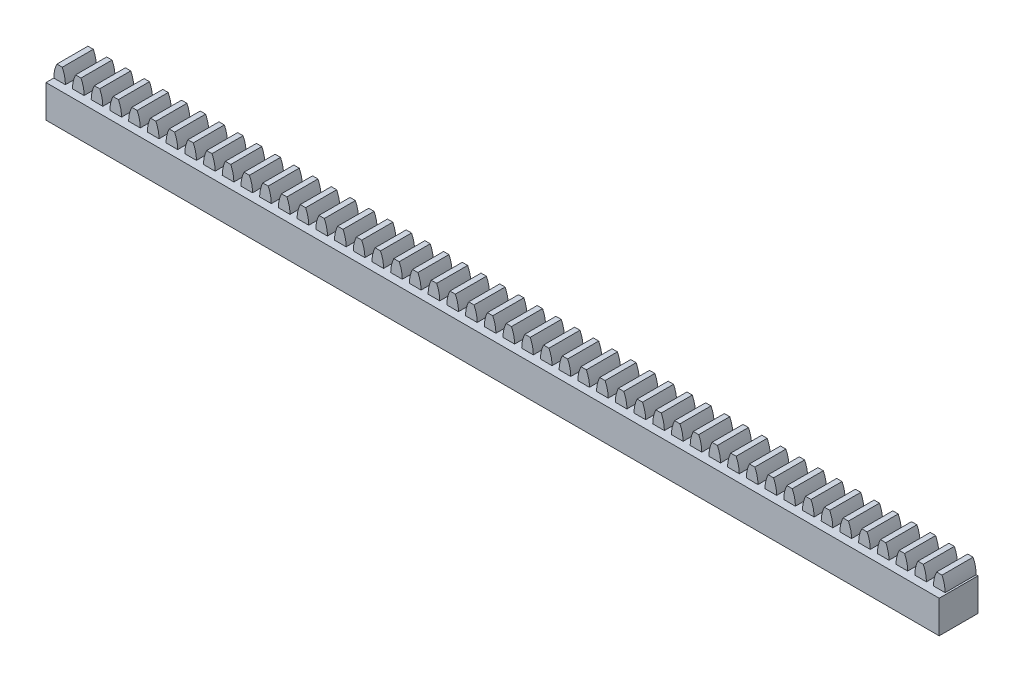
from build123d import *

# Parameters (mm, degrees)
RESSALTO_EXTRUS_O1_DEPTH      = 2
RESSALTO_EXTRUS_O1_2_DEPTH    = 2
RESSALTO_EXTRUS_O1_3_DEPTH    = 2
RESSALTO_EXTRUS_O1_4_DEPTH    = 2
RESSALTO_EXTRUS_O1_5_DEPTH    = 2
RESSALTO_EXTRUS_O1_6_DEPTH    = 2
RESSALTO_EXTRUS_O1_7_DEPTH    = 2
RESSALTO_EXTRUS_O1_8_DEPTH    = 2
RESSALTO_EXTRUS_O1_9_DEPTH    = 2
RESSALTO_EXTRUS_O1_10_DEPTH   = 2
RESSALTO_EXTRUS_O1_11_DEPTH   = 2
RESSALTO_EXTRUS_O1_12_DEPTH   = 2
RESSALTO_EXTRUS_O1_13_DEPTH   = 2
RESSALTO_EXTRUS_O1_14_DEPTH   = 2
RESSALTO_EXTRUS_O1_15_DEPTH   = 2
RESSALTO_EXTRUS_O1_16_DEPTH   = 2
RESSALTO_EXTRUS_O1_17_DEPTH   = 2
RESSALTO_EXTRUS_O1_18_DEPTH   = 2
RESSALTO_EXTRUS_O1_19_DEPTH   = 2
RESSALTO_EXTRUS_O1_20_DEPTH   = 2
RESSALTO_EXTRUS_O1_21_DEPTH   = 2
RESSALTO_EXTRUS_O1_22_DEPTH   = 2
RESSALTO_EXTRUS_O1_23_DEPTH   = 2
RESSALTO_EXTRUS_O1_24_DEPTH   = 2
RESSALTO_EXTRUS_O1_25_DEPTH   = 2
RESSALTO_EXTRUS_O1_26_DEPTH   = 2
RESSALTO_EXTRUS_O1_27_DEPTH   = 2
RESSALTO_EXTRUS_O1_28_DEPTH   = 2
RESSALTO_EXTRUS_O1_29_DEPTH   = 2
RESSALTO_EXTRUS_O1_30_DEPTH   = 2
RESSALTO_EXTRUS_O1_31_DEPTH   = 2
RESSALTO_EXTRUS_O1_32_DEPTH   = 2
RESSALTO_EXTRUS_O1_33_DEPTH   = 2
RESSALTO_EXTRUS_O1_34_DEPTH   = 2
RESSALTO_EXTRUS_O1_35_DEPTH   = 2
RESSALTO_EXTRUS_O1_36_DEPTH   = 2
RESSALTO_EXTRUS_O1_37_DEPTH   = 2
RESSALTO_EXTRUS_O1_38_DEPTH   = 2
RESSALTO_EXTRUS_O1_39_DEPTH   = 2
RESSALTO_EXTRUS_O1_40_DEPTH   = 2
RESSALTO_EXTRUS_O1_41_DEPTH   = 2
RESSALTO_EXTRUS_O1_42_DEPTH   = 2
RESSALTO_EXTRUS_O1_43_DEPTH   = 2
RESSALTO_EXTRUS_O1_44_DEPTH   = 2
RESSALTO_EXTRUS_O1_45_DEPTH   = 2
RESSALTO_EXTRUS_O1_46_DEPTH   = 2
RESSALTO_EXTRUS_O1_47_DEPTH   = 2
RESSALTO_EXTRUS_O1_48_DEPTH   = 2
RESSALTO_EXTRUS_O2_DEPTH      = 3
RESSALTO_EXTRUS_O2_DEPTH_BACK = 2
ESBO_O1_7_W                   = 115
ESBO_O1_7_H                   = 4.2


with BuildPart() as part:
    # Esboço1 → Ressalto-extrusão1 (new, symmetric)
    with BuildSketch(Plane.XY):
        with BuildLine():
            Line((-1.017526261, 4.529689969), (-1.711247382, 4.529689969))
            ThreePointArc((-1.711247382, 4.529689969), (-2.010696446, 3.673045524), (-2.112202188, 2.771266155))
            Line((-2.112202188, 2.771266155), (-0.616571456, 2.771266155))
            ThreePointArc((-0.616571456, 2.771266155), (-0.718077198, 3.673045524), (-1.017526261, 4.529689969))
        make_face()
    extrude(amount=RESSALTO_EXTRUS_O1_DEPTH, both=True)



with BuildPart() as body_2:
    # Esboço1 → Ressalto-extrus_o1 2 (new, symmetric)
    with BuildSketch(Plane.XY):
        with BuildLine():
            ThreePointArc((0.698752618, 4.529689969), (0.399303554, 3.673045524), (0.297797812, 2.771266155))
            Line((0.297797812, 2.771266155), (1.793428544, 2.771266155))
            ThreePointArc((1.793428544, 2.771266155), (1.691922802, 3.673045524), (1.392473739, 4.529689969))
            Line((1.392473739, 4.529689969), (0.698752618, 4.529689969))
        make_face()
    extrude(amount=RESSALTO_EXTRUS_O1_2_DEPTH, both=True)


with BuildPart() as body_3:
    # Esboço1 → Ressalto-extrus_o1 3 (new, symmetric)
    with BuildSketch(Plane.XY):
        with BuildLine():
            ThreePointArc((3.108752618, 4.529689969), (2.809303554, 3.673045524), (2.707797812, 2.771266155))
            Line((2.707797812, 2.771266155), (4.203428544, 2.771266155))
            ThreePointArc((4.203428544, 2.771266155), (4.101922802, 3.673045524), (3.802473739, 4.529689969))
            Line((3.802473739, 4.529689969), (3.108752618, 4.529689969))
        make_face()
    extrude(amount=RESSALTO_EXTRUS_O1_3_DEPTH, both=True)


with BuildPart() as body_4:
    # Esboço1 → Ressalto-extrus_o1 4 (new, symmetric)
    with BuildSketch(Plane.XY):
        with BuildLine():
            ThreePointArc((77.818752618, 4.529689969), (77.519303554, 3.673045524), (77.417797812, 2.771266155))
            Line((77.417797812, 2.771266155), (78.913428544, 2.771266155))
            ThreePointArc((78.913428544, 2.771266155), (78.811922802, 3.673045524), (78.512473739, 4.529689969))
            Line((78.512473739, 4.529689969), (77.818752618, 4.529689969))
        make_face()
    extrude(amount=RESSALTO_EXTRUS_O1_4_DEPTH, both=True)


with BuildPart() as body_5:
    # Esboço1 → Ressalto-extrus_o1 5 (new, symmetric)
    with BuildSketch(Plane.XY):
        with BuildLine():
            Line((75.007797812, 2.771266155), (76.503428544, 2.771266155))
            ThreePointArc((76.503428544, 2.771266155), (76.401922802, 3.673045524), (76.102473739, 4.529689969))
            Line((76.102473739, 4.529689969), (75.408752618, 4.529689969))
            ThreePointArc((75.408752618, 4.529689969), (75.109303554, 3.673045524), (75.007797812, 2.771266155))
        make_face()
    extrude(amount=RESSALTO_EXTRUS_O1_5_DEPTH, both=True)


with BuildPart() as body_6:
    # Esboço1 → Ressalto-extrus_o1 6 (new, symmetric)
    with BuildSketch(Plane.XY):
        with BuildLine():
            ThreePointArc((5.518752618, 4.529689969), (5.219303554, 3.673045524), (5.117797812, 2.771266155))
            Line((5.117797812, 2.771266155), (6.613428544, 2.771266155))
            ThreePointArc((6.613428544, 2.771266155), (6.511922802, 3.673045524), (6.212473739, 4.529689969))
            Line((6.212473739, 4.529689969), (5.518752618, 4.529689969))
        make_face()
    extrude(amount=RESSALTO_EXTRUS_O1_6_DEPTH, both=True)


with BuildPart() as body_7:
    # Esboço1 → Ressalto-extrus_o1 7 (new, symmetric)
    with BuildSketch(Plane.XY):
        with BuildLine():
            ThreePointArc((80.228752618, 4.529689969), (79.929303554, 3.673045524), (79.827797812, 2.771266155))
            Line((79.827797812, 2.771266155), (81.323428544, 2.771266155))
            ThreePointArc((81.323428544, 2.771266155), (81.221922802, 3.673045524), (80.922473739, 4.529689969))
            Line((80.922473739, 4.529689969), (80.228752618, 4.529689969))
        make_face()
    extrude(amount=RESSALTO_EXTRUS_O1_7_DEPTH, both=True)


with BuildPart() as body_8:
    # Esboço1 → Ressalto-extrus_o1 8 (new, symmetric)
    with BuildSketch(Plane.XY):
        with BuildLine():
            Line((111.157797812, 2.771266155), (112.653428544, 2.771266155))
            ThreePointArc((112.653428544, 2.771266155), (112.551922802, 3.673045524), (112.252473739, 4.529689969))
            Line((112.252473739, 4.529689969), (111.558752618, 4.529689969))
            ThreePointArc((111.558752618, 4.529689969), (111.259303554, 3.673045524), (111.157797812, 2.771266155))
        make_face()
    extrude(amount=RESSALTO_EXTRUS_O1_8_DEPTH, both=True)


with BuildPart() as body_9:
    # Esboço1 → Ressalto-extrus_o1 9 (new, symmetric)
    with BuildSketch(Plane.XY):
        with BuildLine():
            Line((72.597797812, 2.771266155), (74.093428544, 2.771266155))
            ThreePointArc((74.093428544, 2.771266155), (73.991922802, 3.673045524), (73.692473739, 4.529689969))
            Line((73.692473739, 4.529689969), (72.998752618, 4.529689969))
            ThreePointArc((72.998752618, 4.529689969), (72.699303554, 3.673045524), (72.597797812, 2.771266155))
        make_face()
    extrude(amount=RESSALTO_EXTRUS_O1_9_DEPTH, both=True)


with BuildPart() as body_10:
    # Esboço1 → Ressalto-extrus_o1 10 (new, symmetric)
    with BuildSketch(Plane.XY):
        with BuildLine():
            ThreePointArc((7.928752618, 4.529689969), (7.629303554, 3.673045524), (7.527797812, 2.771266155))
            Line((7.527797812, 2.771266155), (9.023428544, 2.771266155))
            ThreePointArc((9.023428544, 2.771266155), (8.921922802, 3.673045524), (8.622473739, 4.529689969))
            Line((8.622473739, 4.529689969), (7.928752618, 4.529689969))
        make_face()
    extrude(amount=RESSALTO_EXTRUS_O1_10_DEPTH, both=True)


with BuildPart() as body_11:
    # Esboço1 → Ressalto-extrus_o1 11 (new, symmetric)
    with BuildSketch(Plane.XY):
        with BuildLine():
            ThreePointArc((82.638752618, 4.529689969), (82.339303554, 3.673045524), (82.237797812, 2.771266155))
            Line((82.237797812, 2.771266155), (83.733428544, 2.771266155))
            ThreePointArc((83.733428544, 2.771266155), (83.631922802, 3.673045524), (83.332473739, 4.529689969))
            Line((83.332473739, 4.529689969), (82.638752618, 4.529689969))
        make_face()
    extrude(amount=RESSALTO_EXTRUS_O1_11_DEPTH, both=True)


with BuildPart() as body_12:
    # Esboço1 → Ressalto-extrus_o1 12 (new, symmetric)
    with BuildSketch(Plane.XY):
        with BuildLine():
            Line((108.747797812, 2.771266155), (110.243428544, 2.771266155))
            ThreePointArc((110.243428544, 2.771266155), (110.141922802, 3.673045524), (109.842473739, 4.529689969))
            Line((109.842473739, 4.529689969), (109.148752618, 4.529689969))
            ThreePointArc((109.148752618, 4.529689969), (108.849303554, 3.673045524), (108.747797812, 2.771266155))
        make_face()
    extrude(amount=RESSALTO_EXTRUS_O1_12_DEPTH, both=True)


with BuildPart() as body_13:
    # Esboço1 → Ressalto-extrus_o1 13 (new, symmetric)
    with BuildSketch(Plane.XY):
        with BuildLine():
            Line((70.187797812, 2.771266155), (71.683428544, 2.771266155))
            ThreePointArc((71.683428544, 2.771266155), (71.581922802, 3.673045524), (71.282473739, 4.529689969))
            Line((71.282473739, 4.529689969), (70.588752618, 4.529689969))
            ThreePointArc((70.588752618, 4.529689969), (70.289303554, 3.673045524), (70.187797812, 2.771266155))
        make_face()
    extrude(amount=RESSALTO_EXTRUS_O1_13_DEPTH, both=True)


with BuildPart() as body_14:
    # Esboço1 → Ressalto-extrus_o1 14 (new, symmetric)
    with BuildSketch(Plane.XY):
        with BuildLine():
            ThreePointArc((10.338752618, 4.529689969), (10.039303554, 3.673045524), (9.937797812, 2.771266155))
            Line((9.937797812, 2.771266155), (11.433428544, 2.771266155))
            ThreePointArc((11.433428544, 2.771266155), (11.331922802, 3.673045524), (11.032473739, 4.529689969))
            Line((11.032473739, 4.529689969), (10.338752618, 4.529689969))
        make_face()
    extrude(amount=RESSALTO_EXTRUS_O1_14_DEPTH, both=True)


with BuildPart() as body_15:
    # Esboço1 → Ressalto-extrus_o1 15 (new, symmetric)
    with BuildSketch(Plane.XY):
        with BuildLine():
            ThreePointArc((85.048752618, 4.529689969), (84.749303554, 3.673045524), (84.647797812, 2.771266155))
            Line((84.647797812, 2.771266155), (86.143428544, 2.771266155))
            ThreePointArc((86.143428544, 2.771266155), (86.041922802, 3.673045524), (85.742473739, 4.529689969))
            Line((85.742473739, 4.529689969), (85.048752618, 4.529689969))
        make_face()
    extrude(amount=RESSALTO_EXTRUS_O1_15_DEPTH, both=True)


with BuildPart() as body_16:
    # Esboço1 → Ressalto-extrus_o1 16 (new, symmetric)
    with BuildSketch(Plane.XY):
        with BuildLine():
            Line((106.337797812, 2.771266155), (107.833428544, 2.771266155))
            ThreePointArc((107.833428544, 2.771266155), (107.731922802, 3.673045524), (107.432473739, 4.529689969))
            Line((107.432473739, 4.529689969), (106.738752618, 4.529689969))
            ThreePointArc((106.738752618, 4.529689969), (106.439303554, 3.673045524), (106.337797812, 2.771266155))
        make_face()
    extrude(amount=RESSALTO_EXTRUS_O1_16_DEPTH, both=True)


with BuildPart() as body_17:
    # Esboço1 → Ressalto-extrus_o1 17 (new, symmetric)
    with BuildSketch(Plane.XY):
        with BuildLine():
            Line((67.777797812, 2.771266155), (69.273428544, 2.771266155))
            ThreePointArc((69.273428544, 2.771266155), (69.171922802, 3.673045524), (68.872473739, 4.529689969))
            Line((68.872473739, 4.529689969), (68.178752618, 4.529689969))
            ThreePointArc((68.178752618, 4.529689969), (67.879303554, 3.673045524), (67.777797812, 2.771266155))
        make_face()
    extrude(amount=RESSALTO_EXTRUS_O1_17_DEPTH, both=True)


with BuildPart() as body_18:
    # Esboço1 → Ressalto-extrus_o1 18 (new, symmetric)
    with BuildSketch(Plane.XY):
        with BuildLine():
            ThreePointArc((12.748752618, 4.529689969), (12.449303554, 3.673045524), (12.347797812, 2.771266155))
            Line((12.347797812, 2.771266155), (13.843428544, 2.771266155))
            ThreePointArc((13.843428544, 2.771266155), (13.741922802, 3.673045524), (13.442473739, 4.529689969))
            Line((13.442473739, 4.529689969), (12.748752618, 4.529689969))
        make_face()
    extrude(amount=RESSALTO_EXTRUS_O1_18_DEPTH, both=True)


with BuildPart() as body_19:
    # Esboço1 → Ressalto-extrus_o1 19 (new, symmetric)
    with BuildSketch(Plane.XY):
        with BuildLine():
            ThreePointArc((87.458752618, 4.529689969), (87.159303554, 3.673045524), (87.057797812, 2.771266155))
            Line((87.057797812, 2.771266155), (88.553428544, 2.771266155))
            ThreePointArc((88.553428544, 2.771266155), (88.451922802, 3.673045524), (88.152473739, 4.529689969))
            Line((88.152473739, 4.529689969), (87.458752618, 4.529689969))
        make_face()
    extrude(amount=RESSALTO_EXTRUS_O1_19_DEPTH, both=True)


with BuildPart() as body_20:
    # Esboço1 → Ressalto-extrus_o1 20 (new, symmetric)
    with BuildSketch(Plane.XY):
        with BuildLine():
            Line((103.927797812, 2.771266155), (105.423428544, 2.771266155))
            ThreePointArc((105.423428544, 2.771266155), (105.321922802, 3.673045524), (105.022473739, 4.529689969))
            Line((105.022473739, 4.529689969), (104.328752618, 4.529689969))
            ThreePointArc((104.328752618, 4.529689969), (104.029303554, 3.673045524), (103.927797812, 2.771266155))
        make_face()
    extrude(amount=RESSALTO_EXTRUS_O1_20_DEPTH, both=True)


with BuildPart() as body_21:
    # Esboço1 → Ressalto-extrus_o1 21 (new, symmetric)
    with BuildSketch(Plane.XY):
        with BuildLine():
            Line((65.367797812, 2.771266155), (66.863428544, 2.771266155))
            ThreePointArc((66.863428544, 2.771266155), (66.761922802, 3.673045524), (66.462473739, 4.529689969))
            Line((66.462473739, 4.529689969), (65.768752618, 4.529689969))
            ThreePointArc((65.768752618, 4.529689969), (65.469303554, 3.673045524), (65.367797812, 2.771266155))
        make_face()
    extrude(amount=RESSALTO_EXTRUS_O1_21_DEPTH, both=True)


with BuildPart() as body_22:
    # Esboço1 → Ressalto-extrus_o1 22 (new, symmetric)
    with BuildSketch(Plane.XY):
        with BuildLine():
            ThreePointArc((15.158752618, 4.529689969), (14.859303554, 3.673045524), (14.757797812, 2.771266155))
            Line((14.757797812, 2.771266155), (16.253428544, 2.771266155))
            ThreePointArc((16.253428544, 2.771266155), (16.151922802, 3.673045524), (15.852473739, 4.529689969))
            Line((15.852473739, 4.529689969), (15.158752618, 4.529689969))
        make_face()
    extrude(amount=RESSALTO_EXTRUS_O1_22_DEPTH, both=True)


with BuildPart() as body_23:
    # Esboço1 → Ressalto-extrus_o1 23 (new, symmetric)
    with BuildSketch(Plane.XY):
        with BuildLine():
            ThreePointArc((89.868752618, 4.529689969), (89.569303554, 3.673045524), (89.467797812, 2.771266155))
            Line((89.467797812, 2.771266155), (90.963428544, 2.771266155))
            ThreePointArc((90.963428544, 2.771266155), (90.861922802, 3.673045524), (90.562473739, 4.529689969))
            Line((90.562473739, 4.529689969), (89.868752618, 4.529689969))
        make_face()
    extrude(amount=RESSALTO_EXTRUS_O1_23_DEPTH, both=True)


with BuildPart() as body_24:
    # Esboço1 → Ressalto-extrus_o1 24 (new, symmetric)
    with BuildSketch(Plane.XY):
        with BuildLine():
            Line((101.517797812, 2.771266155), (103.013428544, 2.771266155))
            ThreePointArc((103.013428544, 2.771266155), (102.911922802, 3.673045524), (102.612473739, 4.529689969))
            Line((102.612473739, 4.529689969), (101.918752618, 4.529689969))
            ThreePointArc((101.918752618, 4.529689969), (101.619303554, 3.673045524), (101.517797812, 2.771266155))
        make_face()
    extrude(amount=RESSALTO_EXTRUS_O1_24_DEPTH, both=True)


with BuildPart() as body_25:
    # Esboço1 → Ressalto-extrus_o1 25 (new, symmetric)
    with BuildSketch(Plane.XY):
        with BuildLine():
            Line((62.957797812, 2.771266155), (64.453428544, 2.771266155))
            ThreePointArc((64.453428544, 2.771266155), (64.351922802, 3.673045524), (64.052473739, 4.529689969))
            Line((64.052473739, 4.529689969), (63.358752618, 4.529689969))
            ThreePointArc((63.358752618, 4.529689969), (63.059303554, 3.673045524), (62.957797812, 2.771266155))
        make_face()
    extrude(amount=RESSALTO_EXTRUS_O1_25_DEPTH, both=True)


with BuildPart() as body_26:
    # Esboço1 → Ressalto-extrus_o1 26 (new, symmetric)
    with BuildSketch(Plane.XY):
        with BuildLine():
            ThreePointArc((17.568752618, 4.529689969), (17.269303554, 3.673045524), (17.167797812, 2.771266155))
            Line((17.167797812, 2.771266155), (18.663428544, 2.771266155))
            ThreePointArc((18.663428544, 2.771266155), (18.561922802, 3.673045524), (18.262473739, 4.529689969))
            Line((18.262473739, 4.529689969), (17.568752618, 4.529689969))
        make_face()
    extrude(amount=RESSALTO_EXTRUS_O1_26_DEPTH, both=True)


with BuildPart() as body_27:
    # Esboço1 → Ressalto-extrus_o1 27 (new, symmetric)
    with BuildSketch(Plane.XY):
        with BuildLine():
            ThreePointArc((92.278752618, 4.529689969), (91.979303554, 3.673045524), (91.877797812, 2.771266155))
            Line((91.877797812, 2.771266155), (93.373428544, 2.771266155))
            ThreePointArc((93.373428544, 2.771266155), (93.271922802, 3.673045524), (92.972473739, 4.529689969))
            Line((92.972473739, 4.529689969), (92.278752618, 4.529689969))
        make_face()
    extrude(amount=RESSALTO_EXTRUS_O1_27_DEPTH, both=True)


with BuildPart() as body_28:
    # Esboço1 → Ressalto-extrus_o1 28 (new, symmetric)
    with BuildSketch(Plane.XY):
        with BuildLine():
            Line((99.107797812, 2.771266155), (100.603428544, 2.771266155))
            ThreePointArc((100.603428544, 2.771266155), (100.501922802, 3.673045524), (100.202473739, 4.529689969))
            Line((100.202473739, 4.529689969), (99.508752618, 4.529689969))
            ThreePointArc((99.508752618, 4.529689969), (99.209303554, 3.673045524), (99.107797812, 2.771266155))
        make_face()
    extrude(amount=RESSALTO_EXTRUS_O1_28_DEPTH, both=True)


with BuildPart() as body_29:
    # Esboço1 → Ressalto-extrus_o1 29 (new, symmetric)
    with BuildSketch(Plane.XY):
        with BuildLine():
            Line((60.547797812, 2.771266155), (62.043428544, 2.771266155))
            ThreePointArc((62.043428544, 2.771266155), (61.941922802, 3.673045524), (61.642473739, 4.529689969))
            Line((61.642473739, 4.529689969), (60.948752618, 4.529689969))
            ThreePointArc((60.948752618, 4.529689969), (60.649303554, 3.673045524), (60.547797812, 2.771266155))
        make_face()
    extrude(amount=RESSALTO_EXTRUS_O1_29_DEPTH, both=True)


with BuildPart() as body_30:
    # Esboço1 → Ressalto-extrus_o1 30 (new, symmetric)
    with BuildSketch(Plane.XY):
        with BuildLine():
            ThreePointArc((19.978752618, 4.529689969), (19.679303554, 3.673045524), (19.577797812, 2.771266155))
            Line((19.577797812, 2.771266155), (21.073428544, 2.771266155))
            ThreePointArc((21.073428544, 2.771266155), (20.971922802, 3.673045524), (20.672473739, 4.529689969))
            Line((20.672473739, 4.529689969), (19.978752618, 4.529689969))
        make_face()
    extrude(amount=RESSALTO_EXTRUS_O1_30_DEPTH, both=True)


with BuildPart() as body_31:
    # Esboço1 → Ressalto-extrus_o1 31 (new, symmetric)
    with BuildSketch(Plane.XY):
        with BuildLine():
            ThreePointArc((94.688752618, 4.529689969), (94.389303554, 3.673045524), (94.287797812, 2.771266155))
            Line((94.287797812, 2.771266155), (95.783428544, 2.771266155))
            ThreePointArc((95.783428544, 2.771266155), (95.681922802, 3.673045524), (95.382473739, 4.529689969))
            Line((95.382473739, 4.529689969), (94.688752618, 4.529689969))
        make_face()
    extrude(amount=RESSALTO_EXTRUS_O1_31_DEPTH, both=True)


with BuildPart() as body_32:
    # Esboço1 → Ressalto-extrus_o1 32 (new, symmetric)
    with BuildSketch(Plane.XY):
        with BuildLine():
            Line((96.697797812, 2.771266155), (98.193428544, 2.771266155))
            ThreePointArc((98.193428544, 2.771266155), (98.091922802, 3.673045524), (97.792473739, 4.529689969))
            Line((97.792473739, 4.529689969), (97.098752618, 4.529689969))
            ThreePointArc((97.098752618, 4.529689969), (96.799303554, 3.673045524), (96.697797812, 2.771266155))
        make_face()
    extrude(amount=RESSALTO_EXTRUS_O1_32_DEPTH, both=True)


with BuildPart() as body_33:
    # Esboço1 → Ressalto-extrus_o1 33 (new, symmetric)
    with BuildSketch(Plane.XY):
        with BuildLine():
            Line((58.137797812, 2.771266155), (59.633428544, 2.771266155))
            ThreePointArc((59.633428544, 2.771266155), (59.531922802, 3.673045524), (59.232473739, 4.529689969))
            Line((59.232473739, 4.529689969), (58.538752618, 4.529689969))
            ThreePointArc((58.538752618, 4.529689969), (58.239303554, 3.673045524), (58.137797812, 2.771266155))
        make_face()
    extrude(amount=RESSALTO_EXTRUS_O1_33_DEPTH, both=True)


with BuildPart() as body_34:
    # Esboço1 → Ressalto-extrus_o1 34 (new, symmetric)
    with BuildSketch(Plane.XY):
        with BuildLine():
            ThreePointArc((22.388752618, 4.529689969), (22.089303554, 3.673045524), (21.987797812, 2.771266155))
            Line((21.987797812, 2.771266155), (23.483428544, 2.771266155))
            ThreePointArc((23.483428544, 2.771266155), (23.381922802, 3.673045524), (23.082473739, 4.529689969))
            Line((23.082473739, 4.529689969), (22.388752618, 4.529689969))
        make_face()
    extrude(amount=RESSALTO_EXTRUS_O1_34_DEPTH, both=True)


with BuildPart() as body_35:
    # Esboço1 → Ressalto-extrus_o1 35 (new, symmetric)
    with BuildSketch(Plane.XY):
        with BuildLine():
            Line((55.727797812, 2.771266155), (57.223428544, 2.771266155))
            ThreePointArc((57.223428544, 2.771266155), (57.121922802, 3.673045524), (56.822473739, 4.529689969))
            Line((56.822473739, 4.529689969), (56.128752618, 4.529689969))
            ThreePointArc((56.128752618, 4.529689969), (55.829303554, 3.673045524), (55.727797812, 2.771266155))
        make_face()
    extrude(amount=RESSALTO_EXTRUS_O1_35_DEPTH, both=True)


with BuildPart() as body_36:
    # Esboço1 → Ressalto-extrus_o1 36 (new, symmetric)
    with BuildSketch(Plane.XY):
        with BuildLine():
            ThreePointArc((24.798752618, 4.529689969), (24.499303554, 3.673045524), (24.397797812, 2.771266155))
            Line((24.397797812, 2.771266155), (25.893428544, 2.771266155))
            ThreePointArc((25.893428544, 2.771266155), (25.791922802, 3.673045524), (25.492473739, 4.529689969))
            Line((25.492473739, 4.529689969), (24.798752618, 4.529689969))
        make_face()
    extrude(amount=RESSALTO_EXTRUS_O1_36_DEPTH, both=True)


with BuildPart() as body_37:
    # Esboço1 → Ressalto-extrus_o1 37 (new, symmetric)
    with BuildSketch(Plane.XY):
        with BuildLine():
            Line((53.317797812, 2.771266155), (54.813428544, 2.771266155))
            ThreePointArc((54.813428544, 2.771266155), (54.711922802, 3.673045524), (54.412473739, 4.529689969))
            Line((54.412473739, 4.529689969), (53.718752618, 4.529689969))
            ThreePointArc((53.718752618, 4.529689969), (53.419303554, 3.673045524), (53.317797812, 2.771266155))
        make_face()
    extrude(amount=RESSALTO_EXTRUS_O1_37_DEPTH, both=True)


with BuildPart() as body_38:
    # Esboço1 → Ressalto-extrus_o1 38 (new, symmetric)
    with BuildSketch(Plane.XY):
        with BuildLine():
            ThreePointArc((27.208752618, 4.529689969), (26.909303554, 3.673045524), (26.807797812, 2.771266155))
            Line((26.807797812, 2.771266155), (28.303428544, 2.771266155))
            ThreePointArc((28.303428544, 2.771266155), (28.201922802, 3.673045524), (27.902473739, 4.529689969))
            Line((27.902473739, 4.529689969), (27.208752618, 4.529689969))
        make_face()
    extrude(amount=RESSALTO_EXTRUS_O1_38_DEPTH, both=True)


with BuildPart() as body_39:
    # Esboço1 → Ressalto-extrus_o1 39 (new, symmetric)
    with BuildSketch(Plane.XY):
        with BuildLine():
            Line((50.907797812, 2.771266155), (52.403428544, 2.771266155))
            ThreePointArc((52.403428544, 2.771266155), (52.301922802, 3.673045524), (52.002473739, 4.529689969))
            Line((52.002473739, 4.529689969), (51.308752618, 4.529689969))
            ThreePointArc((51.308752618, 4.529689969), (51.009303554, 3.673045524), (50.907797812, 2.771266155))
        make_face()
    extrude(amount=RESSALTO_EXTRUS_O1_39_DEPTH, both=True)


with BuildPart() as body_40:
    # Esboço1 → Ressalto-extrus_o1 40 (new, symmetric)
    with BuildSketch(Plane.XY):
        with BuildLine():
            ThreePointArc((29.618752618, 4.529689969), (29.319303554, 3.673045524), (29.217797812, 2.771266155))
            Line((29.217797812, 2.771266155), (30.713428544, 2.771266155))
            ThreePointArc((30.713428544, 2.771266155), (30.611922802, 3.673045524), (30.312473739, 4.529689969))
            Line((30.312473739, 4.529689969), (29.618752618, 4.529689969))
        make_face()
    extrude(amount=RESSALTO_EXTRUS_O1_40_DEPTH, both=True)


with BuildPart() as body_41:
    # Esboço1 → Ressalto-extrus_o1 41 (new, symmetric)
    with BuildSketch(Plane.XY):
        with BuildLine():
            Line((48.497797812, 2.771266155), (49.993428544, 2.771266155))
            ThreePointArc((49.993428544, 2.771266155), (49.891922802, 3.673045524), (49.592473739, 4.529689969))
            Line((49.592473739, 4.529689969), (48.898752618, 4.529689969))
            ThreePointArc((48.898752618, 4.529689969), (48.599303554, 3.673045524), (48.497797812, 2.771266155))
        make_face()
    extrude(amount=RESSALTO_EXTRUS_O1_41_DEPTH, both=True)


with BuildPart() as body_42:
    # Esboço1 → Ressalto-extrus_o1 42 (new, symmetric)
    with BuildSketch(Plane.XY):
        with BuildLine():
            ThreePointArc((32.028752618, 4.529689969), (31.729303554, 3.673045524), (31.627797812, 2.771266155))
            Line((31.627797812, 2.771266155), (33.123428544, 2.771266155))
            ThreePointArc((33.123428544, 2.771266155), (33.021922802, 3.673045524), (32.722473739, 4.529689969))
            Line((32.722473739, 4.529689969), (32.028752618, 4.529689969))
        make_face()
    extrude(amount=RESSALTO_EXTRUS_O1_42_DEPTH, both=True)


with BuildPart() as body_43:
    # Esboço1 → Ressalto-extrus_o1 43 (new, symmetric)
    with BuildSketch(Plane.XY):
        with BuildLine():
            Line((46.087797812, 2.771266155), (47.583428544, 2.771266155))
            ThreePointArc((47.583428544, 2.771266155), (47.481922802, 3.673045524), (47.182473739, 4.529689969))
            Line((47.182473739, 4.529689969), (46.488752618, 4.529689969))
            ThreePointArc((46.488752618, 4.529689969), (46.189303554, 3.673045524), (46.087797812, 2.771266155))
        make_face()
    extrude(amount=RESSALTO_EXTRUS_O1_43_DEPTH, both=True)


with BuildPart() as body_44:
    # Esboço1 → Ressalto-extrus_o1 44 (new, symmetric)
    with BuildSketch(Plane.XY):
        with BuildLine():
            ThreePointArc((34.438752618, 4.529689969), (34.139303554, 3.673045524), (34.037797812, 2.771266155))
            Line((34.037797812, 2.771266155), (35.533428544, 2.771266155))
            ThreePointArc((35.533428544, 2.771266155), (35.431922802, 3.673045524), (35.132473739, 4.529689969))
            Line((35.132473739, 4.529689969), (34.438752618, 4.529689969))
        make_face()
    extrude(amount=RESSALTO_EXTRUS_O1_44_DEPTH, both=True)


with BuildPart() as body_45:
    # Esboço1 → Ressalto-extrus_o1 45 (new, symmetric)
    with BuildSketch(Plane.XY):
        with BuildLine():
            Line((43.677797812, 2.771266155), (45.173428544, 2.771266155))
            ThreePointArc((45.173428544, 2.771266155), (45.071922802, 3.673045524), (44.772473739, 4.529689969))
            Line((44.772473739, 4.529689969), (44.078752618, 4.529689969))
            ThreePointArc((44.078752618, 4.529689969), (43.779303554, 3.673045524), (43.677797812, 2.771266155))
        make_face()
    extrude(amount=RESSALTO_EXTRUS_O1_45_DEPTH, both=True)


with BuildPart() as body_46:
    # Esboço1 → Ressalto-extrus_o1 46 (new, symmetric)
    with BuildSketch(Plane.XY):
        with BuildLine():
            ThreePointArc((36.848752618, 4.529689969), (36.549303554, 3.673045524), (36.447797812, 2.771266155))
            Line((36.447797812, 2.771266155), (37.943428544, 2.771266155))
            ThreePointArc((37.943428544, 2.771266155), (37.841922802, 3.673045524), (37.542473739, 4.529689969))
            Line((37.542473739, 4.529689969), (36.848752618, 4.529689969))
        make_face()
    extrude(amount=RESSALTO_EXTRUS_O1_46_DEPTH, both=True)


with BuildPart() as body_47:
    # Esboço1 → Ressalto-extrus_o1 47 (new, symmetric)
    with BuildSketch(Plane.XY):
        with BuildLine():
            Line((41.267797812, 2.771266155), (42.763428544, 2.771266155))
            ThreePointArc((42.763428544, 2.771266155), (42.661922802, 3.673045524), (42.362473739, 4.529689969))
            Line((42.362473739, 4.529689969), (41.668752618, 4.529689969))
            ThreePointArc((41.668752618, 4.529689969), (41.369303554, 3.673045524), (41.267797812, 2.771266155))
        make_face()
    extrude(amount=RESSALTO_EXTRUS_O1_47_DEPTH, both=True)


with BuildPart() as body_48:
    # Esboço1 → Ressalto-extrus_o1 48 (new, symmetric)
    with BuildSketch(Plane.XY):
        with BuildLine():
            ThreePointArc((39.258752618, 4.529689969), (38.959303554, 3.673045524), (38.857797812, 2.771266155))
            Line((38.857797812, 2.771266155), (40.353428544, 2.771266155))
            ThreePointArc((40.353428544, 2.771266155), (40.251922802, 3.673045524), (39.952473739, 4.529689969))
            Line((39.952473739, 4.529689969), (39.258752618, 4.529689969))
        make_face()
    extrude(amount=RESSALTO_EXTRUS_O1_48_DEPTH, both=True)


with BuildPart() as part_1:
    add(part.part)

    add(body_2.part)  # Ressalto-extrusão2 merges body 2

    add(body_3.part)  # Ressalto-extrusão2 merges body 3

    add(body_6.part)  # Ressalto-extrusão2 merges body 6

    add(body_10.part)  # Ressalto-extrusão2 merges body 10

    add(body_14.part)  # Ressalto-extrusão2 merges body 14

    add(body_18.part)  # Ressalto-extrusão2 merges body 18

    add(body_22.part)  # Ressalto-extrusão2 merges body 22

    add(body_26.part)  # Ressalto-extrusão2 merges body 26

    add(body_30.part)  # Ressalto-extrusão2 merges body 30

    add(body_34.part)  # Ressalto-extrusão2 merges body 34

    add(body_36.part)  # Ressalto-extrusão2 merges body 36

    add(body_38.part)  # Ressalto-extrusão2 merges body 38

    add(body_40.part)  # Ressalto-extrusão2 merges body 40

    add(body_42.part)  # Ressalto-extrusão2 merges body 42

    add(body_44.part)  # Ressalto-extrusão2 merges body 44

    add(body_46.part)  # Ressalto-extrusão2 merges body 46

    add(body_48.part)  # Ressalto-extrusão2 merges body 48

    add(body_47.part)  # Ressalto-extrusão2 merges body 47

    add(body_45.part)  # Ressalto-extrusão2 merges body 45

    add(body_43.part)  # Ressalto-extrusão2 merges body 43
    # Esboço1<7> → Ressalto-extrusão2 (add, two sides: drawn at the far end of the back side and taken through both)
    with BuildSketch(Plane.XY.offset(-RESSALTO_EXTRUS_O2_DEPTH_BACK)):
        with Locations((55.387797812, 0.671266155)):
            Rectangle(ESBO_O1_7_W, ESBO_O1_7_H)
    extrude(amount=RESSALTO_EXTRUS_O2_DEPTH + RESSALTO_EXTRUS_O2_DEPTH_BACK)


solid = Compound([body_4.part, body_5.part, body_7.part, body_8.part, body_9.part, body_11.part, body_12.part, body_13.part, body_15.part, body_16.part, body_17.part, body_19.part, body_20.part, body_21.part, body_23.part, body_24.part, body_25.part, body_27.part, body_28.part, body_29.part, body_31.part, body_32.part, body_33.part, body_35.part, body_37.part, body_39.part, body_41.part, part_1.part])
